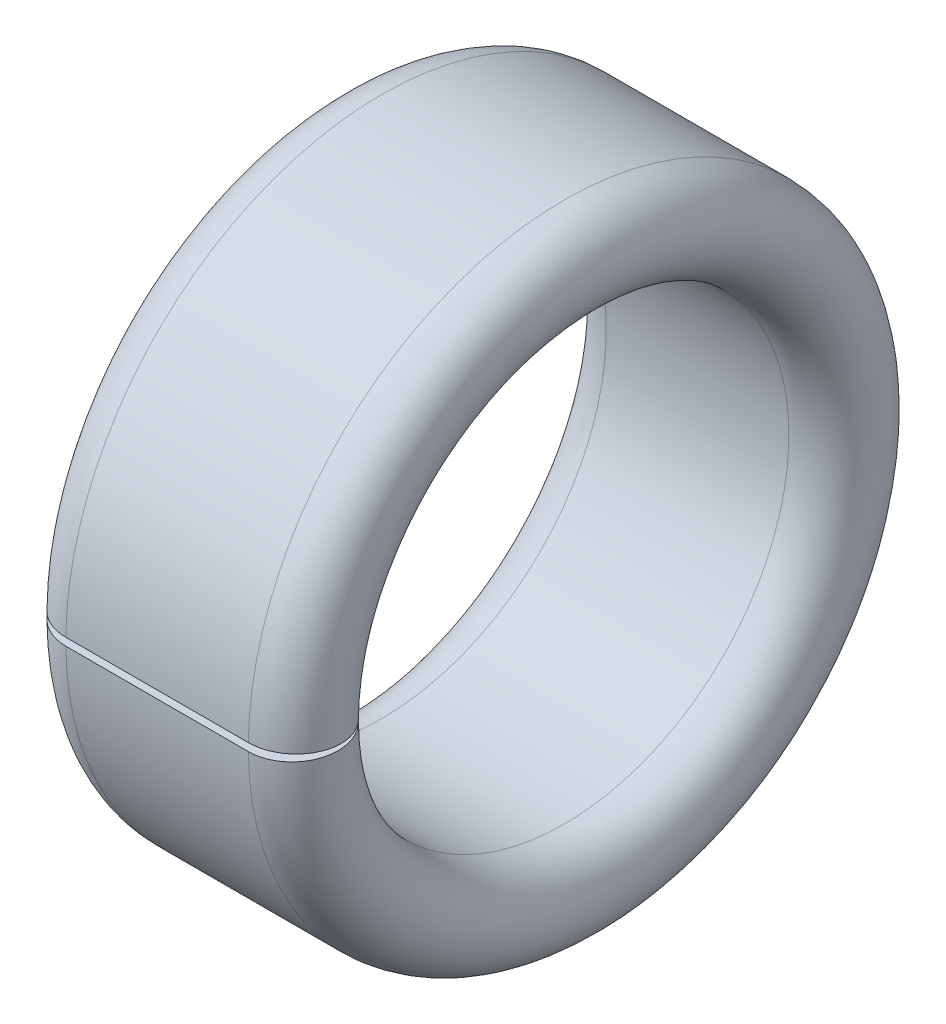
from build123d import *

# Parameters (mm, degrees)
CUT_EXTRUDE1_DEPTH = 3.9


with BuildPart() as part:
    # Sketch1 → Revolve1 (revolve)
    with BuildSketch(Plane.XY):
        with BuildLine():
            Line((0.65, 3.2), (3.25, 3.2))
            ThreePointArc((3.25, 3.2), (3.9, 3.85), (3.25, 4.5))
            Line((3.25, 4.5), (0.65, 4.5))
            ThreePointArc((0.65, 4.5), (0, 3.85), (0.65, 3.2))
        make_face()
    revolve(axis=Axis((3.9, 0, 0), (-1, 0, 0)))

    # Sketch2 → Cut-Extrude1 (cut)
    with BuildSketch(Plane(origin=(0, 0, 0), x_dir=(0, 0, -1), z_dir=(1, 0, 0))):
        with BuildLine():
            Line((-5.499258793, -0.090292432), (-2.913621842, 0))
            Line((-2.913621842, 0), (-5.499258793, 0.090292432))
            ThreePointArc((-5.499258793, 0.090292432), (-5.5, 0), (-5.499258793, -0.090292432))
        make_face()
    extrude(amount=CUT_EXTRUDE1_DEPTH, mode=Mode.SUBTRACT)


solid = part.part
